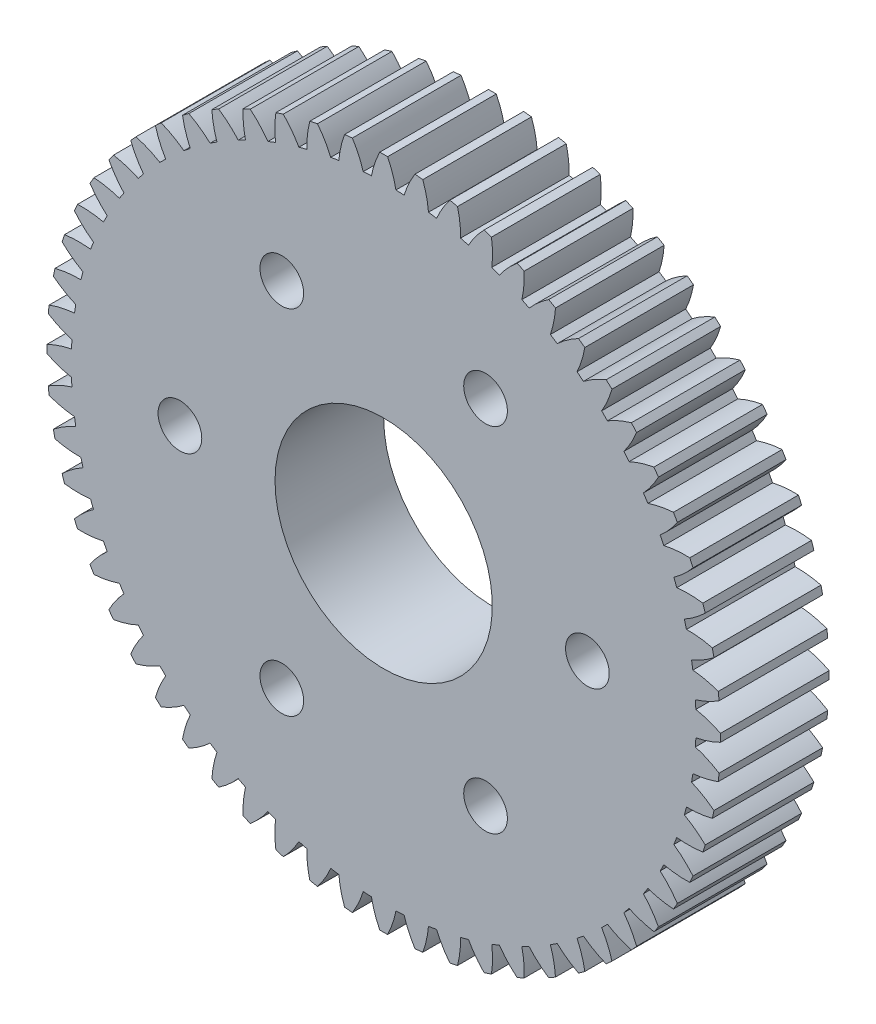
from build123d import *

# Parameters (mm, degrees)
SKETCH1_R              = 39.36992126
BOSS_EXTRUDE1_DEPTH    = 12.6999746
CUT_EXTRUDE1_DEPTH     = 13.6999746
CUT_EXTRUDE2_DEPTH     = 13.6999746
CUT_EXTRUDE3_DEPTH     = 13.6999746
CUT_EXTRUDE4_DEPTH     = 13.6999746
CUT_EXTRUDE5_DEPTH     = 13.6999746
CUT_EXTRUDE6_DEPTH     = 13.6999746
CUT_EXTRUDE7_DEPTH     = 13.6999746
CUT_EXTRUDE8_DEPTH     = 13.6999746
CUT_EXTRUDE9_DEPTH     = 13.6999746
CUT_EXTRUDE10_DEPTH    = 13.6999746
CUT_EXTRUDE11_DEPTH    = 13.6999746
CUT_EXTRUDE12_DEPTH    = 13.6999746
CUT_EXTRUDE13_DEPTH    = 13.6999746
CUT_EXTRUDE14_DEPTH    = 13.6999746
CUT_EXTRUDE15_DEPTH    = 13.6999746
CUT_EXTRUDE16_DEPTH    = 13.6999746
CUT_EXTRUDE17_DEPTH    = 13.6999746
CUT_EXTRUDE18_DEPTH    = 13.6999746
CUT_EXTRUDE19_DEPTH    = 13.6999746
CUT_EXTRUDE20_DEPTH    = 13.6999746
CUT_EXTRUDE21_DEPTH    = 13.6999746
CUT_EXTRUDE22_DEPTH    = 13.6999746
CUT_EXTRUDE23_DEPTH    = 13.6999746
CUT_EXTRUDE24_DEPTH    = 13.6999746
CUT_EXTRUDE25_DEPTH    = 13.6999746
CUT_EXTRUDE26_DEPTH    = 13.6999746
CUT_EXTRUDE27_DEPTH    = 13.6999746
CUT_EXTRUDE28_DEPTH    = 13.6999746
CUT_EXTRUDE29_DEPTH    = 13.6999746
CUT_EXTRUDE30_DEPTH    = 13.6999746
CUT_EXTRUDE31_DEPTH    = 13.6999746
CUT_EXTRUDE32_DEPTH    = 13.6999746
CUT_EXTRUDE33_DEPTH    = 13.6999746
CUT_EXTRUDE34_DEPTH    = 13.6999746
CUT_EXTRUDE35_DEPTH    = 13.6999746
CUT_EXTRUDE36_DEPTH    = 13.6999746
CUT_EXTRUDE37_DEPTH    = 13.6999746
CUT_EXTRUDE38_DEPTH    = 13.6999746
CUT_EXTRUDE39_DEPTH    = 13.6999746
CUT_EXTRUDE40_DEPTH    = 13.6999746
CUT_EXTRUDE41_DEPTH    = 13.6999746
CUT_EXTRUDE42_DEPTH    = 13.6999746
CUT_EXTRUDE43_DEPTH    = 13.6999746
CUT_EXTRUDE44_DEPTH    = 13.6999746
CUT_EXTRUDE45_DEPTH    = 13.6999746
CUT_EXTRUDE46_DEPTH    = 13.6999746
CUT_EXTRUDE47_DEPTH    = 13.6999746
CUT_EXTRUDE48_DEPTH    = 13.6999746
CUT_EXTRUDE49_DEPTH    = 13.6999746
CUT_EXTRUDE50_DEPTH    = 13.6999746
CUT_EXTRUDE51_DEPTH    = 13.6999746
CUT_EXTRUDE52_DEPTH    = 13.6999746
CUT_EXTRUDE53_DEPTH    = 13.6999746
CUT_EXTRUDE54_DEPTH    = 13.6999746
CUT_EXTRUDE55_DEPTH    = 13.6999746
CUT_EXTRUDE56_DEPTH    = 13.6999746
CUT_EXTRUDE57_DEPTH    = 13.6999746
CUT_EXTRUDE58_DEPTH    = 13.6999746
CUT_EXTRUDE59_DEPTH    = 13.6999746
CUT_EXTRUDE60_DEPTH    = 13.6999746
HOLE1_D                = 25.4
HOLE1_DEPTH            = 12.6999746
F_10_CLEARANCE_HOLE1_D = 5.1054


with BuildPart() as part:
    # Sketch1 → Boss-Extrude1 (new body)
    with BuildSketch(Plane.XY):
        with Locations(Location((0, 0, 0), (0, 0, 180))):  # turned: the seam where the file's is
            Circle(SKETCH1_R)
    extrude(amount=-BOSS_EXTRUDE1_DEPTH)

    # Sketch2 → Cut-Extrude1 (cut, through all)
    with BuildSketch(Plane(origin=(0, 0, -12.6999746), x_dir=(-1, 0, 0), z_dir=(0, 0, -1))):
        with BuildLine():
            ThreePointArc((8.632897854, 38.411766097), (8.910906358, 36.912197067), (8.987539423, 35.389001946))
            ThreePointArc((8.987539423, 35.389001946), (9.450111484, 35.268296196), (9.911063515, 35.141544411))
            ThreePointArc((9.911063515, 35.141544411), (10.739027257, 36.422353548), (11.729574199, 37.582014171))
            ThreePointArc((11.729574199, 37.582014171), (10.189685426, 38.028423724), (8.632897854, 38.411766097))
        make_face()
    extrude(amount=-CUT_EXTRUDE1_DEPTH, mode=Mode.SUBTRACT)

    # Sketch3 → Cut-Extrude2 (cut, through all)
    with BuildSketch(Plane(origin=(0, 0, -12.6999746), x_dir=(-1, 0, 0), z_dir=(0, 0, -1))):
        with BuildLine():
            ThreePointArc((12.600728818, 37.298958877), (12.720466716, 35.778544841), (12.637462732, 34.255683606))
            ThreePointArc((12.637462732, 34.255683606), (13.084883588, 34.087287148), (13.530061306, 33.913047115))
            ThreePointArc((13.530061306, 33.913047115), (14.487370387, 35.100294068), (15.593708552, 36.150061599))
            ThreePointArc((15.593708552, 36.150061599), (14.108917956, 36.754987881), (12.600728818, 37.298958877))
        make_face()
    extrude(amount=-CUT_EXTRUDE2_DEPTH, mode=Mode.SUBTRACT)

    # Sketch4 → Cut-Extrude3 (cut, through all)
    with BuildSketch(Plane(origin=(0, 0, -12.6999746), x_dir=(-1, 0, 0), z_dir=(0, 0, -1))):
        with BuildLine():
            ThreePointArc((16.43050356, 35.777496458), (16.390658978, 34.252895391), (16.148927354, 32.747052828))
            ThreePointArc((16.148927354, 32.747052828), (16.576294969, 32.532810649), (17.000820915, 32.312991379))
            ThreePointArc((17.000820915, 32.312991379), (18.076986855, 33.393668422), (19.286994971, 34.322041388))
            ThreePointArc((19.286994971, 34.322041388), (17.873570228, 35.078856699), (16.43050356, 35.777496458))
        make_face()
    extrude(amount=-CUT_EXTRUDE3_DEPTH, mode=Mode.SUBTRACT)

    # Sketch5 → Cut-Extrude4 (cut, through all)
    with BuildSketch(Plane(origin=(0, 0, -12.6999746), x_dir=(-1, 0, 0), z_dir=(0, 0, -1))):
        with BuildLine():
            ThreePointArc((20.080262266, 33.864048301), (19.881271751, 32.351964051), (19.483460949, 30.879638487))
            ThreePointArc((19.483460949, 30.879638487), (19.886092994, 30.621897868), (20.285315971, 30.358907746))
            ThreePointArc((20.285315971, 30.358907746), (21.468548073, 31.321174755), (22.768969036, 32.117981709))
            ThreePointArc((22.768969036, 32.117981709), (21.442395924, 33.018394223), (20.080262266, 33.864048301))
        make_face()
    extrude(amount=-CUT_EXTRUDE4_DEPTH, mode=Mode.SUBTRACT)

    # Sketch6 → Cut-Extrude5 (cut, through all)
    with BuildSketch(Plane(origin=(0, 0, -12.6999746), x_dir=(-1, 0, 0), z_dir=(0, 0, -1))):
        with BuildLine():
            ThreePointArc((23.510017418, 31.579578544), (23.15406115, 30.096577823), (22.604529668, 28.673900364))
            ThreePointArc((22.604529668, 28.673900364), (22.978014822, 28.375485167), (23.347560861, 28.072205568))
            ThreePointArc((23.347560861, 28.072205568), (24.624895385, 28.905519744), (26.001481513, 29.562030701))
            ThreePointArc((26.001481513, 29.562030701), (24.776294243, 30.59617531), (23.510017418, 31.579578544))
        make_face()
    extrude(amount=-CUT_EXTRUDE5_DEPTH, mode=Mode.SUBTRACT)

    # Sketch7 → Cut-Extrude6 (cut, through all)
    with BuildSketch(Plane(origin=(0, 0, -12.6999746), x_dir=(-1, 0, 0), z_dir=(0, 0, -1))):
        with BuildLine():
            ThreePointArc((26.682191898, 28.949116317), (26.17316981, 27.511447191), (25.477938431, 26.154004988))
            ThreePointArc((25.477938431, 26.154004988), (25.818184712, 25.818184712), (26.154004988, 25.477938431))
            ThreePointArc((26.154004988, 25.477938431), (27.511447191, 26.17316981), (28.949116317, 26.682191898))
            ThreePointArc((28.949116317, 26.682191898), (27.838738298, 27.838738298), (26.682191898, 28.949116317))
        make_face()
    extrude(amount=-CUT_EXTRUDE6_DEPTH, mode=Mode.SUBTRACT)

    # Sketch8 → Cut-Extrude7 (cut, through all)
    with BuildSketch(Plane(origin=(0, 0, -12.6999746), x_dir=(-1, 0, 0), z_dir=(0, 0, -1))):
        with BuildLine():
            ThreePointArc((29.562030701, 26.001481513), (28.905519744, 24.624895385), (28.072205568, 23.347560861))
            ThreePointArc((28.072205568, 23.347560861), (28.375485167, 22.978014822), (28.673900364, 22.604529668))
            ThreePointArc((28.673900364, 22.604529668), (30.096577823, 23.15406115), (31.579578544, 23.510017418))
            ThreePointArc((31.579578544, 23.510017418), (30.59617531, 24.776294243), (29.562030701, 26.001481513))
        make_face()
    extrude(amount=-CUT_EXTRUDE7_DEPTH, mode=Mode.SUBTRACT)

    # Sketch9 → Cut-Extrude8 (cut, through all)
    with BuildSketch(Plane(origin=(0, 0, -12.6999746), x_dir=(-1, 0, 0), z_dir=(0, 0, -1))):
        with BuildLine():
            ThreePointArc((32.117981709, 22.768969036), (31.321174755, 21.468548073), (30.358907746, 20.285315971))
            ThreePointArc((30.358907746, 20.285315971), (30.621897868, 19.886092994), (30.879638487, 19.483460949))
            ThreePointArc((30.879638487, 19.483460949), (32.351964051, 19.881271751), (33.864048301, 20.080262266))
            ThreePointArc((33.864048301, 20.080262266), (33.018394223, 21.442395924), (32.117981709, 22.768969036))
        make_face()
    extrude(amount=-CUT_EXTRUDE8_DEPTH, mode=Mode.SUBTRACT)

    # Sketch10 → Cut-Extrude9 (cut, through all)
    with BuildSketch(Plane(origin=(0, 0, -12.6999746), x_dir=(-1, 0, 0), z_dir=(0, 0, -1))):
        with BuildLine():
            ThreePointArc((34.322041388, 19.286994971), (33.393668422, 18.076986855), (32.312991379, 17.000820915))
            ThreePointArc((32.312991379, 17.000820915), (32.532810649, 16.576294969), (32.747052828, 16.148927354))
            ThreePointArc((32.747052828, 16.148927354), (34.252895391, 16.390658978), (35.777496458, 16.43050356))
            ThreePointArc((35.777496458, 16.43050356), (35.078856699, 17.873570228), (34.322041388, 19.286994971))
        make_face()
    extrude(amount=-CUT_EXTRUDE9_DEPTH, mode=Mode.SUBTRACT)

    # Sketch11 → Cut-Extrude10 (cut, through all)
    with BuildSketch(Plane(origin=(0, 0, -12.6999746), x_dir=(-1, 0, 0), z_dir=(0, 0, -1))):
        with BuildLine():
            ThreePointArc((36.150061599, 15.593708552), (35.100294068, 14.487370387), (33.913047115, 13.530061306))
            ThreePointArc((33.913047115, 13.530061306), (34.087287148, 13.084883588), (34.255683606, 12.637462732))
            ThreePointArc((34.255683606, 12.637462732), (35.778544841, 12.720466716), (37.298958877, 12.600728818))
            ThreePointArc((37.298958877, 12.600728818), (36.754987881, 14.108917956), (36.150061599, 15.593708552))
        make_face()
    extrude(amount=-CUT_EXTRUDE10_DEPTH, mode=Mode.SUBTRACT)

    # Sketch12 → Cut-Extrude11 (cut, through all)
    with BuildSketch(Plane(origin=(0, 0, -12.6999746), x_dir=(-1, 0, 0), z_dir=(0, 0, -1))):
        with BuildLine():
            ThreePointArc((37.582014171, 11.729574199), (36.422353548, 10.739027257), (35.141544411, 9.911063515))
            ThreePointArc((35.141544411, 9.911063515), (35.268296196, 9.450111484), (35.389001946, 8.987539423))
            ThreePointArc((35.389001946, 8.987539423), (36.912197067, 8.910906358), (38.411766097, 8.632897854))
            ThreePointArc((38.411766097, 8.632897854), (38.028423724, 10.189685426), (37.582014171, 11.729574199))
        make_face()
    extrude(amount=-CUT_EXTRUDE11_DEPTH, mode=Mode.SUBTRACT)

    # Sketch13 → Cut-Extrude12 (cut, through all)
    with BuildSketch(Plane(origin=(0, 0, -12.6999746), x_dir=(-1, 0, 0), z_dir=(0, 0, -1))):
        with BuildLine():
            ThreePointArc((38.602210331, 7.736928176), (37.345362101, 6.873025097), (35.985023593, 6.183478038))
            ThreePointArc((35.985023593, 6.183478038), (36.06289841, 5.711801981), (36.134590975, 5.239146752))
            ThreePointArc((36.134590975, 5.239146752), (37.641431537, 5.003716245), (39.103725969, 4.570483055))
            ThreePointArc((39.103725969, 4.570483055), (38.885212199, 6.158812571), (38.602210331, 7.736928176))
        make_face()
    extrude(amount=-CUT_EXTRUDE12_DEPTH, mode=Mode.SUBTRACT)

    # Sketch14 → Cut-Extrude13 (cut, through all)
    with BuildSketch(Plane(origin=(0, 0, -12.6999746), x_dir=(-1, 0, 0), z_dir=(0, 0, -1))):
        with BuildLine():
            ThreePointArc((39.199472596, 3.659514749), (37.859207051, 2.931720636), (36.434243325, 2.388145082))
            ThreePointArc((36.434243325, 2.388145082), (36.462387963, 1.91091278), (36.484281863, 1.433352892))
            ThreePointArc((36.484281863, 1.433352892), (37.958258606, 1.04170437), (39.367257237, 0.457993087))
            ThreePointArc((39.367257237, 0.457993087), (39.315966151, 2.060462476), (39.199472596, 3.659514749))
        make_face()
    extrude(amount=-CUT_EXTRUDE13_DEPTH, mode=Mode.SUBTRACT)

    # Sketch15 → Cut-Extrude14 (cut, through all)
    with BuildSketch(Plane(origin=(0, 0, -12.6999746), x_dir=(-1, 0, 0), z_dir=(0, 0, -1))):
        with BuildLine():
            ThreePointArc((39.367257237, -0.457993087), (37.958258606, -1.04170437), (36.484281863, -1.433352892))
            ThreePointArc((36.484281863, -1.433352892), (36.462387963, -1.91091278), (36.434243325, -2.388145082))
            ThreePointArc((36.434243325, -2.388145082), (37.859207051, -2.931720636), (39.199472596, -3.659514749))
            ThreePointArc((39.199472596, -3.659514749), (39.315966151, -2.060462476), (39.367257237, -0.457993087))
        make_face()
    extrude(amount=-CUT_EXTRUDE14_DEPTH, mode=Mode.SUBTRACT)

    # Sketch16 → Cut-Extrude15 (cut, through all)
    with BuildSketch(Plane(origin=(0, 0, -12.6999746), x_dir=(-1, 0, 0), z_dir=(0, 0, -1))):
        with BuildLine():
            ThreePointArc((39.103725969, -4.570483055), (37.641431537, -5.003716245), (36.134590975, -5.239146752))
            ThreePointArc((36.134590975, -5.239146752), (36.06289841, -5.711801981), (35.985023593, -6.183478038))
            ThreePointArc((35.985023593, -6.183478038), (37.345362101, -6.873025097), (38.602210331, -7.736928176))
            ThreePointArc((38.602210331, -7.736928176), (38.885212199, -6.158812571), (39.103725969, -4.570483055))
        make_face()
    extrude(amount=-CUT_EXTRUDE15_DEPTH, mode=Mode.SUBTRACT)

    # Sketch17 → Cut-Extrude16 (cut, through all)
    with BuildSketch(Plane(origin=(0, 0, -12.6999746), x_dir=(-1, 0, 0), z_dir=(0, 0, -1))):
        with BuildLine():
            ThreePointArc((38.411766097, -8.632897854), (36.912197067, -8.910906358), (35.389001946, -8.987539423))
            ThreePointArc((35.389001946, -8.987539423), (35.268296196, -9.450111484), (35.141544411, -9.911063515))
            ThreePointArc((35.141544411, -9.911063515), (36.422353548, -10.739027257), (37.582014171, -11.729574199))
            ThreePointArc((37.582014171, -11.729574199), (38.028423724, -10.189685426), (38.411766097, -8.632897854))
        make_face()
    extrude(amount=-CUT_EXTRUDE16_DEPTH, mode=Mode.SUBTRACT)

    # Sketch18 → Cut-Extrude17 (cut, through all)
    with BuildSketch(Plane(origin=(0, 0, -12.6999746), x_dir=(-1, 0, 0), z_dir=(0, 0, -1))):
        with BuildLine():
            ThreePointArc((37.298958877, -12.600728818), (35.778544841, -12.720466716), (34.255683606, -12.637462732))
            ThreePointArc((34.255683606, -12.637462732), (34.087287148, -13.084883588), (33.913047115, -13.530061306))
            ThreePointArc((33.913047115, -13.530061306), (35.100294068, -14.487370387), (36.150061599, -15.593708552))
            ThreePointArc((36.150061599, -15.593708552), (36.754987881, -14.108917956), (37.298958877, -12.600728818))
        make_face()
    extrude(amount=-CUT_EXTRUDE17_DEPTH, mode=Mode.SUBTRACT)

    # Sketch19 → Cut-Extrude18 (cut, through all)
    with BuildSketch(Plane(origin=(0, 0, -12.6999746), x_dir=(-1, 0, 0), z_dir=(0, 0, -1))):
        with BuildLine():
            ThreePointArc((35.777496458, -16.43050356), (34.252895391, -16.390658978), (32.747052828, -16.148927354))
            ThreePointArc((32.747052828, -16.148927354), (32.532810649, -16.576294969), (32.312991379, -17.000820915))
            ThreePointArc((32.312991379, -17.000820915), (33.393668422, -18.076986855), (34.322041388, -19.286994971))
            ThreePointArc((34.322041388, -19.286994971), (35.078856699, -17.873570228), (35.777496458, -16.43050356))
        make_face()
    extrude(amount=-CUT_EXTRUDE18_DEPTH, mode=Mode.SUBTRACT)

    # Sketch20 → Cut-Extrude19 (cut, through all)
    with BuildSketch(Plane(origin=(0, 0, -12.6999746), x_dir=(-1, 0, 0), z_dir=(0, 0, -1))):
        with BuildLine():
            ThreePointArc((33.864048301, -20.080262266), (32.351964051, -19.881271751), (30.879638487, -19.483460949))
            ThreePointArc((30.879638487, -19.483460949), (30.621897868, -19.886092994), (30.358907746, -20.285315971))
            ThreePointArc((30.358907746, -20.285315971), (31.321174755, -21.468548073), (32.117981709, -22.768969036))
            ThreePointArc((32.117981709, -22.768969036), (33.018394223, -21.442395924), (33.864048301, -20.080262266))
        make_face()
    extrude(amount=-CUT_EXTRUDE19_DEPTH, mode=Mode.SUBTRACT)

    # Sketch21 → Cut-Extrude20 (cut, through all)
    with BuildSketch(Plane(origin=(0, 0, -12.6999746), x_dir=(-1, 0, 0), z_dir=(0, 0, -1))):
        with BuildLine():
            ThreePointArc((31.579578544, -23.510017418), (30.096577823, -23.15406115), (28.673900364, -22.604529668))
            ThreePointArc((28.673900364, -22.604529668), (28.375485167, -22.978014822), (28.072205568, -23.347560861))
            ThreePointArc((28.072205568, -23.347560861), (28.905519744, -24.624895385), (29.562030701, -26.001481513))
            ThreePointArc((29.562030701, -26.001481513), (30.59617531, -24.776294243), (31.579578544, -23.510017418))
        make_face()
    extrude(amount=-CUT_EXTRUDE20_DEPTH, mode=Mode.SUBTRACT)

    # Sketch22 → Cut-Extrude21 (cut, through all)
    with BuildSketch(Plane(origin=(0, 0, -12.6999746), x_dir=(-1, 0, 0), z_dir=(0, 0, -1))):
        with BuildLine():
            ThreePointArc((28.949116317, -26.682191898), (27.511447191, -26.17316981), (26.154004988, -25.477938431))
            ThreePointArc((26.154004988, -25.477938431), (25.818184712, -25.818184712), (25.477938431, -26.154004988))
            ThreePointArc((25.477938431, -26.154004988), (26.17316981, -27.511447191), (26.682191898, -28.949116317))
            ThreePointArc((26.682191898, -28.949116317), (27.838738298, -27.838738298), (28.949116317, -26.682191898))
        make_face()
    extrude(amount=-CUT_EXTRUDE21_DEPTH, mode=Mode.SUBTRACT)

    # Sketch23 → Cut-Extrude22 (cut, through all)
    with BuildSketch(Plane(origin=(0, 0, -12.6999746), x_dir=(-1, 0, 0), z_dir=(0, 0, -1))):
        with BuildLine():
            ThreePointArc((26.001481513, -29.562030701), (24.624895385, -28.905519744), (23.347560861, -28.072205568))
            ThreePointArc((23.347560861, -28.072205568), (22.978014822, -28.375485167), (22.604529668, -28.673900364))
            ThreePointArc((22.604529668, -28.673900364), (23.15406115, -30.096577823), (23.510017418, -31.579578544))
            ThreePointArc((23.510017418, -31.579578544), (24.776294243, -30.59617531), (26.001481513, -29.562030701))
        make_face()
    extrude(amount=-CUT_EXTRUDE22_DEPTH, mode=Mode.SUBTRACT)

    # Sketch24 → Cut-Extrude23 (cut, through all)
    with BuildSketch(Plane(origin=(0, 0, -12.6999746), x_dir=(-1, 0, 0), z_dir=(0, 0, -1))):
        with BuildLine():
            ThreePointArc((22.768969036, -32.117981709), (21.468548073, -31.321174755), (20.285315971, -30.358907746))
            ThreePointArc((20.285315971, -30.358907746), (19.886092994, -30.621897868), (19.483460949, -30.879638487))
            ThreePointArc((19.483460949, -30.879638487), (19.881271751, -32.351964051), (20.080262266, -33.864048301))
            ThreePointArc((20.080262266, -33.864048301), (21.442395924, -33.018394223), (22.768969036, -32.117981709))
        make_face()
    extrude(amount=-CUT_EXTRUDE23_DEPTH, mode=Mode.SUBTRACT)

    # Sketch25 → Cut-Extrude24 (cut, through all)
    with BuildSketch(Plane(origin=(0, 0, -12.6999746), x_dir=(-1, 0, 0), z_dir=(0, 0, -1))):
        with BuildLine():
            ThreePointArc((19.286994971, -34.322041388), (18.076986855, -33.393668422), (17.000820915, -32.312991379))
            ThreePointArc((17.000820915, -32.312991379), (16.576294969, -32.532810649), (16.148927354, -32.747052828))
            ThreePointArc((16.148927354, -32.747052828), (16.390658978, -34.252895391), (16.43050356, -35.777496458))
            ThreePointArc((16.43050356, -35.777496458), (17.873570228, -35.078856699), (19.286994971, -34.322041388))
        make_face()
    extrude(amount=-CUT_EXTRUDE24_DEPTH, mode=Mode.SUBTRACT)

    # Sketch26 → Cut-Extrude25 (cut, through all)
    with BuildSketch(Plane(origin=(0, 0, -12.6999746), x_dir=(-1, 0, 0), z_dir=(0, 0, -1))):
        with BuildLine():
            ThreePointArc((15.593708552, -36.150061599), (14.487370387, -35.100294068), (13.530061306, -33.913047115))
            ThreePointArc((13.530061306, -33.913047115), (13.084883588, -34.087287148), (12.637462732, -34.255683606))
            ThreePointArc((12.637462732, -34.255683606), (12.720466716, -35.778544841), (12.600728818, -37.298958877))
            ThreePointArc((12.600728818, -37.298958877), (14.108917956, -36.754987881), (15.593708552, -36.150061599))
        make_face()
    extrude(amount=-CUT_EXTRUDE25_DEPTH, mode=Mode.SUBTRACT)

    # Sketch27 → Cut-Extrude26 (cut, through all)
    with BuildSketch(Plane(origin=(0, 0, -12.6999746), x_dir=(-1, 0, 0), z_dir=(0, 0, -1))):
        with BuildLine():
            ThreePointArc((11.729574199, -37.582014171), (10.739027257, -36.422353548), (9.911063515, -35.141544411))
            ThreePointArc((9.911063515, -35.141544411), (9.450111484, -35.268296196), (8.987539423, -35.389001946))
            ThreePointArc((8.987539423, -35.389001946), (8.910906358, -36.912197067), (8.632897854, -38.411766097))
            ThreePointArc((8.632897854, -38.411766097), (10.189685426, -38.028423724), (11.729574199, -37.582014171))
        make_face()
    extrude(amount=-CUT_EXTRUDE26_DEPTH, mode=Mode.SUBTRACT)

    # Sketch28 → Cut-Extrude27 (cut, through all)
    with BuildSketch(Plane(origin=(0, 0, -12.6999746), x_dir=(-1, 0, 0), z_dir=(0, 0, -1))):
        with BuildLine():
            ThreePointArc((7.736928176, -38.602210331), (6.873025097, -37.345362101), (6.183478038, -35.985023593))
            ThreePointArc((6.183478038, -35.985023593), (5.711801981, -36.06289841), (5.239146752, -36.134590975))
            ThreePointArc((5.239146752, -36.134590975), (5.003716245, -37.641431537), (4.570483055, -39.103725969))
            ThreePointArc((4.570483055, -39.103725969), (6.158812571, -38.885212199), (7.736928176, -38.602210331))
        make_face()
    extrude(amount=-CUT_EXTRUDE27_DEPTH, mode=Mode.SUBTRACT)

    # Sketch29 → Cut-Extrude28 (cut, through all)
    with BuildSketch(Plane(origin=(0, 0, -12.6999746), x_dir=(-1, 0, 0), z_dir=(0, 0, -1))):
        with BuildLine():
            ThreePointArc((3.659514749, -39.199472596), (2.931720636, -37.859207051), (2.388145082, -36.434243325))
            ThreePointArc((2.388145082, -36.434243325), (1.91091278, -36.462387963), (1.433352892, -36.484281863))
            ThreePointArc((1.433352892, -36.484281863), (1.04170437, -37.958258606), (0.457993087, -39.367257237))
            ThreePointArc((0.457993087, -39.367257237), (2.060462476, -39.315966151), (3.659514749, -39.199472596))
        make_face()
    extrude(amount=-CUT_EXTRUDE28_DEPTH, mode=Mode.SUBTRACT)

    # Sketch30 → Cut-Extrude29 (cut, through all)
    with BuildSketch(Plane(origin=(0, 0, -12.6999746), x_dir=(-1, 0, 0), z_dir=(0, 0, -1))):
        with BuildLine():
            ThreePointArc((-0.457993087, -39.367257237), (-1.04170437, -37.958258606), (-1.433352892, -36.484281863))
            ThreePointArc((-1.433352892, -36.484281863), (-1.91091278, -36.462387963), (-2.388145082, -36.434243325))
            ThreePointArc((-2.388145082, -36.434243325), (-2.931720636, -37.859207051), (-3.659514749, -39.199472596))
            ThreePointArc((-3.659514749, -39.199472596), (-2.060462476, -39.315966151), (-0.457993087, -39.367257237))
        make_face()
    extrude(amount=-CUT_EXTRUDE29_DEPTH, mode=Mode.SUBTRACT)

    # Sketch31 → Cut-Extrude30 (cut, through all)
    with BuildSketch(Plane(origin=(0, 0, -12.6999746), x_dir=(-1, 0, 0), z_dir=(0, 0, -1))):
        with BuildLine():
            ThreePointArc((-4.570483055, -39.103725969), (-5.003716245, -37.641431537), (-5.239146752, -36.134590975))
            ThreePointArc((-5.239146752, -36.134590975), (-5.711801981, -36.06289841), (-6.183478038, -35.985023593))
            ThreePointArc((-6.183478038, -35.985023593), (-6.873025097, -37.345362101), (-7.736928176, -38.602210331))
            ThreePointArc((-7.736928176, -38.602210331), (-6.158812571, -38.885212199), (-4.570483055, -39.103725969))
        make_face()
    extrude(amount=-CUT_EXTRUDE30_DEPTH, mode=Mode.SUBTRACT)

    # Sketch32 → Cut-Extrude31 (cut, through all)
    with BuildSketch(Plane(origin=(0, 0, -12.6999746), x_dir=(-1, 0, 0), z_dir=(0, 0, -1))):
        with BuildLine():
            ThreePointArc((-8.632897854, -38.411766097), (-8.910906358, -36.912197067), (-8.987539423, -35.389001946))
            ThreePointArc((-8.987539423, -35.389001946), (-9.450111484, -35.268296196), (-9.911063515, -35.141544411))
            ThreePointArc((-9.911063515, -35.141544411), (-10.739027257, -36.422353548), (-11.729574199, -37.582014171))
            ThreePointArc((-11.729574199, -37.582014171), (-10.189685426, -38.028423724), (-8.632897854, -38.411766097))
        make_face()
    extrude(amount=-CUT_EXTRUDE31_DEPTH, mode=Mode.SUBTRACT)

    # Sketch33 → Cut-Extrude32 (cut, through all)
    with BuildSketch(Plane(origin=(0, 0, -12.6999746), x_dir=(-1, 0, 0), z_dir=(0, 0, -1))):
        with BuildLine():
            ThreePointArc((-12.600728818, -37.298958877), (-12.720466716, -35.778544841), (-12.637462732, -34.255683606))
            ThreePointArc((-12.637462732, -34.255683606), (-13.084883588, -34.087287148), (-13.530061306, -33.913047115))
            ThreePointArc((-13.530061306, -33.913047115), (-14.487370387, -35.100294068), (-15.593708552, -36.150061599))
            ThreePointArc((-15.593708552, -36.150061599), (-14.108917956, -36.754987881), (-12.600728818, -37.298958877))
        make_face()
    extrude(amount=-CUT_EXTRUDE32_DEPTH, mode=Mode.SUBTRACT)

    # Sketch34 → Cut-Extrude33 (cut, through all)
    with BuildSketch(Plane(origin=(0, 0, -12.6999746), x_dir=(-1, 0, 0), z_dir=(0, 0, -1))):
        with BuildLine():
            ThreePointArc((-16.43050356, -35.777496458), (-16.390658978, -34.252895391), (-16.148927354, -32.747052828))
            ThreePointArc((-16.148927354, -32.747052828), (-16.576294969, -32.532810649), (-17.000820915, -32.312991379))
            ThreePointArc((-17.000820915, -32.312991379), (-18.076986855, -33.393668422), (-19.286994971, -34.322041388))
            ThreePointArc((-19.286994971, -34.322041388), (-17.873570228, -35.078856699), (-16.43050356, -35.777496458))
        make_face()
    extrude(amount=-CUT_EXTRUDE33_DEPTH, mode=Mode.SUBTRACT)

    # Sketch35 → Cut-Extrude34 (cut, through all)
    with BuildSketch(Plane(origin=(0, 0, -12.6999746), x_dir=(-1, 0, 0), z_dir=(0, 0, -1))):
        with BuildLine():
            ThreePointArc((-20.080262266, -33.864048301), (-19.881271751, -32.351964051), (-19.483460949, -30.879638487))
            ThreePointArc((-19.483460949, -30.879638487), (-19.886092994, -30.621897868), (-20.285315971, -30.358907746))
            ThreePointArc((-20.285315971, -30.358907746), (-21.468548073, -31.321174755), (-22.768969036, -32.117981709))
            ThreePointArc((-22.768969036, -32.117981709), (-21.442395924, -33.018394223), (-20.080262266, -33.864048301))
        make_face()
    extrude(amount=-CUT_EXTRUDE34_DEPTH, mode=Mode.SUBTRACT)

    # Sketch36 → Cut-Extrude35 (cut, through all)
    with BuildSketch(Plane(origin=(0, 0, -12.6999746), x_dir=(-1, 0, 0), z_dir=(0, 0, -1))):
        with BuildLine():
            ThreePointArc((-23.510017418, -31.579578544), (-23.15406115, -30.096577823), (-22.604529668, -28.673900364))
            ThreePointArc((-22.604529668, -28.673900364), (-22.978014822, -28.375485167), (-23.347560861, -28.072205568))
            ThreePointArc((-23.347560861, -28.072205568), (-24.624895385, -28.905519744), (-26.001481513, -29.562030701))
            ThreePointArc((-26.001481513, -29.562030701), (-24.776294243, -30.59617531), (-23.510017418, -31.579578544))
        make_face()
    extrude(amount=-CUT_EXTRUDE35_DEPTH, mode=Mode.SUBTRACT)

    # Sketch37 → Cut-Extrude36 (cut, through all)
    with BuildSketch(Plane(origin=(0, 0, -12.6999746), x_dir=(-1, 0, 0), z_dir=(0, 0, -1))):
        with BuildLine():
            ThreePointArc((-26.682191898, -28.949116317), (-26.17316981, -27.511447191), (-25.477938431, -26.154004988))
            ThreePointArc((-25.477938431, -26.154004988), (-25.818184712, -25.818184712), (-26.154004988, -25.477938431))
            ThreePointArc((-26.154004988, -25.477938431), (-27.511447191, -26.17316981), (-28.949116317, -26.682191898))
            ThreePointArc((-28.949116317, -26.682191898), (-27.838738298, -27.838738298), (-26.682191898, -28.949116317))
        make_face()
    extrude(amount=-CUT_EXTRUDE36_DEPTH, mode=Mode.SUBTRACT)

    # Sketch38 → Cut-Extrude37 (cut, through all)
    with BuildSketch(Plane(origin=(0, 0, -12.6999746), x_dir=(-1, 0, 0), z_dir=(0, 0, -1))):
        with BuildLine():
            ThreePointArc((-29.562030701, -26.001481513), (-28.905519744, -24.624895385), (-28.072205568, -23.347560861))
            ThreePointArc((-28.072205568, -23.347560861), (-28.375485167, -22.978014822), (-28.673900364, -22.604529668))
            ThreePointArc((-28.673900364, -22.604529668), (-30.096577823, -23.15406115), (-31.579578544, -23.510017418))
            ThreePointArc((-31.579578544, -23.510017418), (-30.59617531, -24.776294243), (-29.562030701, -26.001481513))
        make_face()
    extrude(amount=-CUT_EXTRUDE37_DEPTH, mode=Mode.SUBTRACT)

    # Sketch39 → Cut-Extrude38 (cut, through all)
    with BuildSketch(Plane(origin=(0, 0, -12.6999746), x_dir=(-1, 0, 0), z_dir=(0, 0, -1))):
        with BuildLine():
            ThreePointArc((-32.117981709, -22.768969036), (-31.321174755, -21.468548073), (-30.358907746, -20.285315971))
            ThreePointArc((-30.358907746, -20.285315971), (-30.621897868, -19.886092994), (-30.879638487, -19.483460949))
            ThreePointArc((-30.879638487, -19.483460949), (-32.351964051, -19.881271751), (-33.864048301, -20.080262266))
            ThreePointArc((-33.864048301, -20.080262266), (-33.018394223, -21.442395924), (-32.117981709, -22.768969036))
        make_face()
    extrude(amount=-CUT_EXTRUDE38_DEPTH, mode=Mode.SUBTRACT)

    # Sketch40 → Cut-Extrude39 (cut, through all)
    with BuildSketch(Plane(origin=(0, 0, -12.6999746), x_dir=(-1, 0, 0), z_dir=(0, 0, -1))):
        with BuildLine():
            ThreePointArc((-34.322041388, -19.286994971), (-33.393668422, -18.076986855), (-32.312991379, -17.000820915))
            ThreePointArc((-32.312991379, -17.000820915), (-32.532810649, -16.576294969), (-32.747052828, -16.148927354))
            ThreePointArc((-32.747052828, -16.148927354), (-34.252895391, -16.390658978), (-35.777496458, -16.43050356))
            ThreePointArc((-35.777496458, -16.43050356), (-35.078856699, -17.873570228), (-34.322041388, -19.286994971))
        make_face()
    extrude(amount=-CUT_EXTRUDE39_DEPTH, mode=Mode.SUBTRACT)

    # Sketch41 → Cut-Extrude40 (cut, through all)
    with BuildSketch(Plane(origin=(0, 0, -12.6999746), x_dir=(-1, 0, 0), z_dir=(0, 0, -1))):
        with BuildLine():
            ThreePointArc((-36.150061599, -15.593708552), (-35.100294068, -14.487370387), (-33.913047115, -13.530061306))
            ThreePointArc((-33.913047115, -13.530061306), (-34.087287148, -13.084883588), (-34.255683606, -12.637462732))
            ThreePointArc((-34.255683606, -12.637462732), (-35.778544841, -12.720466716), (-37.298958877, -12.600728818))
            ThreePointArc((-37.298958877, -12.600728818), (-36.754987881, -14.108917956), (-36.150061599, -15.593708552))
        make_face()
    extrude(amount=-CUT_EXTRUDE40_DEPTH, mode=Mode.SUBTRACT)

    # Sketch42 → Cut-Extrude41 (cut, through all)
    with BuildSketch(Plane(origin=(0, 0, -12.6999746), x_dir=(-1, 0, 0), z_dir=(0, 0, -1))):
        with BuildLine():
            ThreePointArc((-37.582014171, -11.729574199), (-36.422353548, -10.739027257), (-35.141544411, -9.911063515))
            ThreePointArc((-35.141544411, -9.911063515), (-35.268296196, -9.450111484), (-35.389001946, -8.987539423))
            ThreePointArc((-35.389001946, -8.987539423), (-36.912197067, -8.910906358), (-38.411766097, -8.632897854))
            ThreePointArc((-38.411766097, -8.632897854), (-38.028423724, -10.189685426), (-37.582014171, -11.729574199))
        make_face()
    extrude(amount=-CUT_EXTRUDE41_DEPTH, mode=Mode.SUBTRACT)

    # Sketch43 → Cut-Extrude42 (cut, through all)
    with BuildSketch(Plane(origin=(0, 0, -12.6999746), x_dir=(-1, 0, 0), z_dir=(0, 0, -1))):
        with BuildLine():
            ThreePointArc((-38.602210331, -7.736928176), (-37.345362101, -6.873025097), (-35.985023593, -6.183478038))
            ThreePointArc((-35.985023593, -6.183478038), (-36.06289841, -5.711801981), (-36.134590975, -5.239146752))
            ThreePointArc((-36.134590975, -5.239146752), (-37.641431537, -5.003716245), (-39.103725969, -4.570483055))
            ThreePointArc((-39.103725969, -4.570483055), (-38.885212199, -6.158812571), (-38.602210331, -7.736928176))
        make_face()
    extrude(amount=-CUT_EXTRUDE42_DEPTH, mode=Mode.SUBTRACT)

    # Sketch44 → Cut-Extrude43 (cut, through all)
    with BuildSketch(Plane(origin=(0, 0, -12.6999746), x_dir=(-1, 0, 0), z_dir=(0, 0, -1))):
        with BuildLine():
            ThreePointArc((-39.199472596, -3.659514749), (-37.859207051, -2.931720636), (-36.434243325, -2.388145082))
            ThreePointArc((-36.434243325, -2.388145082), (-36.462387963, -1.91091278), (-36.484281863, -1.433352892))
            ThreePointArc((-36.484281863, -1.433352892), (-37.958258606, -1.04170437), (-39.367257237, -0.457993087))
            ThreePointArc((-39.367257237, -0.457993087), (-39.315966151, -2.060462476), (-39.199472596, -3.659514749))
        make_face()
    extrude(amount=-CUT_EXTRUDE43_DEPTH, mode=Mode.SUBTRACT)

    # Sketch45 → Cut-Extrude44 (cut, through all)
    with BuildSketch(Plane(origin=(0, 0, -12.6999746), x_dir=(-1, 0, 0), z_dir=(0, 0, -1))):
        with BuildLine():
            ThreePointArc((-39.367257237, 0.457993087), (-37.958258606, 1.04170437), (-36.484281863, 1.433352892))
            ThreePointArc((-36.484281863, 1.433352892), (-36.462387963, 1.91091278), (-36.434243325, 2.388145082))
            ThreePointArc((-36.434243325, 2.388145082), (-37.859207051, 2.931720636), (-39.199472596, 3.659514749))
            ThreePointArc((-39.199472596, 3.659514749), (-39.315966151, 2.060462476), (-39.367257237, 0.457993087))
        make_face()
    extrude(amount=-CUT_EXTRUDE44_DEPTH, mode=Mode.SUBTRACT)

    # Sketch46 → Cut-Extrude45 (cut, through all)
    with BuildSketch(Plane(origin=(0, 0, -12.6999746), x_dir=(-1, 0, 0), z_dir=(0, 0, -1))):
        with BuildLine():
            ThreePointArc((-39.103725969, 4.570483055), (-37.641431537, 5.003716245), (-36.134590975, 5.239146752))
            ThreePointArc((-36.134590975, 5.239146752), (-36.06289841, 5.711801981), (-35.985023593, 6.183478038))
            ThreePointArc((-35.985023593, 6.183478038), (-37.345362101, 6.873025097), (-38.602210331, 7.736928176))
            ThreePointArc((-38.602210331, 7.736928176), (-38.885212199, 6.158812571), (-39.103725969, 4.570483055))
        make_face()
    extrude(amount=-CUT_EXTRUDE45_DEPTH, mode=Mode.SUBTRACT)

    # Sketch47 → Cut-Extrude46 (cut, through all)
    with BuildSketch(Plane(origin=(0, 0, -12.6999746), x_dir=(-1, 0, 0), z_dir=(0, 0, -1))):
        with BuildLine():
            ThreePointArc((-38.411766097, 8.632897854), (-36.912197067, 8.910906358), (-35.389001946, 8.987539423))
            ThreePointArc((-35.389001946, 8.987539423), (-35.268296196, 9.450111484), (-35.141544411, 9.911063515))
            ThreePointArc((-35.141544411, 9.911063515), (-36.422353548, 10.739027257), (-37.582014171, 11.729574199))
            ThreePointArc((-37.582014171, 11.729574199), (-38.028423724, 10.189685426), (-38.411766097, 8.632897854))
        make_face()
    extrude(amount=-CUT_EXTRUDE46_DEPTH, mode=Mode.SUBTRACT)

    # Sketch48 → Cut-Extrude47 (cut, through all)
    with BuildSketch(Plane(origin=(0, 0, -12.6999746), x_dir=(-1, 0, 0), z_dir=(0, 0, -1))):
        with BuildLine():
            ThreePointArc((-37.298958877, 12.600728818), (-35.778544841, 12.720466716), (-34.255683606, 12.637462732))
            ThreePointArc((-34.255683606, 12.637462732), (-34.087287148, 13.084883588), (-33.913047115, 13.530061306))
            ThreePointArc((-33.913047115, 13.530061306), (-35.100294068, 14.487370387), (-36.150061599, 15.593708552))
            ThreePointArc((-36.150061599, 15.593708552), (-36.754987881, 14.108917956), (-37.298958877, 12.600728818))
        make_face()
    extrude(amount=-CUT_EXTRUDE47_DEPTH, mode=Mode.SUBTRACT)

    # Sketch49 → Cut-Extrude48 (cut, through all)
    with BuildSketch(Plane(origin=(0, 0, -12.6999746), x_dir=(-1, 0, 0), z_dir=(0, 0, -1))):
        with BuildLine():
            ThreePointArc((-35.777496458, 16.43050356), (-34.252895391, 16.390658978), (-32.747052828, 16.148927354))
            ThreePointArc((-32.747052828, 16.148927354), (-32.532810649, 16.576294969), (-32.312991379, 17.000820915))
            ThreePointArc((-32.312991379, 17.000820915), (-33.393668422, 18.076986855), (-34.322041388, 19.286994971))
            ThreePointArc((-34.322041388, 19.286994971), (-35.078856699, 17.873570228), (-35.777496458, 16.43050356))
        make_face()
    extrude(amount=-CUT_EXTRUDE48_DEPTH, mode=Mode.SUBTRACT)

    # Sketch50 → Cut-Extrude49 (cut, through all)
    with BuildSketch(Plane(origin=(0, 0, -12.6999746), x_dir=(-1, 0, 0), z_dir=(0, 0, -1))):
        with BuildLine():
            ThreePointArc((-33.864048301, 20.080262266), (-32.351964051, 19.881271751), (-30.879638487, 19.483460949))
            ThreePointArc((-30.879638487, 19.483460949), (-30.621897868, 19.886092994), (-30.358907746, 20.285315971))
            ThreePointArc((-30.358907746, 20.285315971), (-31.321174755, 21.468548073), (-32.117981709, 22.768969036))
            ThreePointArc((-32.117981709, 22.768969036), (-33.018394223, 21.442395924), (-33.864048301, 20.080262266))
        make_face()
    extrude(amount=-CUT_EXTRUDE49_DEPTH, mode=Mode.SUBTRACT)

    # Sketch51 → Cut-Extrude50 (cut, through all)
    with BuildSketch(Plane(origin=(0, 0, -12.6999746), x_dir=(-1, 0, 0), z_dir=(0, 0, -1))):
        with BuildLine():
            ThreePointArc((-31.579578544, 23.510017418), (-30.096577823, 23.15406115), (-28.673900364, 22.604529668))
            ThreePointArc((-28.673900364, 22.604529668), (-28.375485167, 22.978014822), (-28.072205568, 23.347560861))
            ThreePointArc((-28.072205568, 23.347560861), (-28.905519744, 24.624895385), (-29.562030701, 26.001481513))
            ThreePointArc((-29.562030701, 26.001481513), (-30.59617531, 24.776294243), (-31.579578544, 23.510017418))
        make_face()
    extrude(amount=-CUT_EXTRUDE50_DEPTH, mode=Mode.SUBTRACT)

    # Sketch52 → Cut-Extrude51 (cut, through all)
    with BuildSketch(Plane(origin=(0, 0, -12.6999746), x_dir=(-1, 0, 0), z_dir=(0, 0, -1))):
        with BuildLine():
            ThreePointArc((-28.949116317, 26.682191898), (-27.511447191, 26.17316981), (-26.154004988, 25.477938431))
            ThreePointArc((-26.154004988, 25.477938431), (-25.818184712, 25.818184712), (-25.477938431, 26.154004988))
            ThreePointArc((-25.477938431, 26.154004988), (-26.17316981, 27.511447191), (-26.682191898, 28.949116317))
            ThreePointArc((-26.682191898, 28.949116317), (-27.838738298, 27.838738298), (-28.949116317, 26.682191898))
        make_face()
    extrude(amount=-CUT_EXTRUDE51_DEPTH, mode=Mode.SUBTRACT)

    # Sketch53 → Cut-Extrude52 (cut, through all)
    with BuildSketch(Plane(origin=(0, 0, -12.6999746), x_dir=(-1, 0, 0), z_dir=(0, 0, -1))):
        with BuildLine():
            ThreePointArc((-26.001481513, 29.562030701), (-24.624895385, 28.905519744), (-23.347560861, 28.072205568))
            ThreePointArc((-23.347560861, 28.072205568), (-22.978014822, 28.375485167), (-22.604529668, 28.673900364))
            ThreePointArc((-22.604529668, 28.673900364), (-23.15406115, 30.096577823), (-23.510017418, 31.579578544))
            ThreePointArc((-23.510017418, 31.579578544), (-24.776294243, 30.59617531), (-26.001481513, 29.562030701))
        make_face()
    extrude(amount=-CUT_EXTRUDE52_DEPTH, mode=Mode.SUBTRACT)

    # Sketch54 → Cut-Extrude53 (cut, through all)
    with BuildSketch(Plane(origin=(0, 0, -12.6999746), x_dir=(-1, 0, 0), z_dir=(0, 0, -1))):
        with BuildLine():
            ThreePointArc((-22.768969036, 32.117981709), (-21.468548073, 31.321174755), (-20.285315971, 30.358907746))
            ThreePointArc((-20.285315971, 30.358907746), (-19.886092994, 30.621897868), (-19.483460949, 30.879638487))
            ThreePointArc((-19.483460949, 30.879638487), (-19.881271751, 32.351964051), (-20.080262266, 33.864048301))
            ThreePointArc((-20.080262266, 33.864048301), (-21.442395924, 33.018394223), (-22.768969036, 32.117981709))
        make_face()
    extrude(amount=-CUT_EXTRUDE53_DEPTH, mode=Mode.SUBTRACT)

    # Sketch55 → Cut-Extrude54 (cut, through all)
    with BuildSketch(Plane(origin=(0, 0, -12.6999746), x_dir=(-1, 0, 0), z_dir=(0, 0, -1))):
        with BuildLine():
            ThreePointArc((-19.286994971, 34.322041388), (-18.076986855, 33.393668422), (-17.000820915, 32.312991379))
            ThreePointArc((-17.000820915, 32.312991379), (-16.576294969, 32.532810649), (-16.148927354, 32.747052828))
            ThreePointArc((-16.148927354, 32.747052828), (-16.390658978, 34.252895391), (-16.43050356, 35.777496458))
            ThreePointArc((-16.43050356, 35.777496458), (-17.873570228, 35.078856699), (-19.286994971, 34.322041388))
        make_face()
    extrude(amount=-CUT_EXTRUDE54_DEPTH, mode=Mode.SUBTRACT)

    # Sketch56 → Cut-Extrude55 (cut, through all)
    with BuildSketch(Plane(origin=(0, 0, -12.6999746), x_dir=(-1, 0, 0), z_dir=(0, 0, -1))):
        with BuildLine():
            ThreePointArc((-15.593708552, 36.150061599), (-14.487370387, 35.100294068), (-13.530061306, 33.913047115))
            ThreePointArc((-13.530061306, 33.913047115), (-13.084883588, 34.087287148), (-12.637462732, 34.255683606))
            ThreePointArc((-12.637462732, 34.255683606), (-12.720466716, 35.778544841), (-12.600728818, 37.298958877))
            ThreePointArc((-12.600728818, 37.298958877), (-14.108917956, 36.754987881), (-15.593708552, 36.150061599))
        make_face()
    extrude(amount=-CUT_EXTRUDE55_DEPTH, mode=Mode.SUBTRACT)

    # Sketch57 → Cut-Extrude56 (cut, through all)
    with BuildSketch(Plane(origin=(0, 0, -12.6999746), x_dir=(-1, 0, 0), z_dir=(0, 0, -1))):
        with BuildLine():
            ThreePointArc((-11.729574199, 37.582014171), (-10.739027257, 36.422353548), (-9.911063515, 35.141544411))
            ThreePointArc((-9.911063515, 35.141544411), (-9.450111484, 35.268296196), (-8.987539423, 35.389001946))
            ThreePointArc((-8.987539423, 35.389001946), (-8.910906358, 36.912197067), (-8.632897854, 38.411766097))
            ThreePointArc((-8.632897854, 38.411766097), (-10.189685426, 38.028423724), (-11.729574199, 37.582014171))
        make_face()
    extrude(amount=-CUT_EXTRUDE56_DEPTH, mode=Mode.SUBTRACT)

    # Sketch58 → Cut-Extrude57 (cut, through all)
    with BuildSketch(Plane(origin=(0, 0, -12.6999746), x_dir=(-1, 0, 0), z_dir=(0, 0, -1))):
        with BuildLine():
            ThreePointArc((-7.736928176, 38.602210331), (-6.873025097, 37.345362101), (-6.183478038, 35.985023593))
            ThreePointArc((-6.183478038, 35.985023593), (-5.711801981, 36.06289841), (-5.239146752, 36.134590975))
            ThreePointArc((-5.239146752, 36.134590975), (-5.003716245, 37.641431537), (-4.570483055, 39.103725969))
            ThreePointArc((-4.570483055, 39.103725969), (-6.158812571, 38.885212199), (-7.736928176, 38.602210331))
        make_face()
    extrude(amount=-CUT_EXTRUDE57_DEPTH, mode=Mode.SUBTRACT)

    # Sketch59 → Cut-Extrude58 (cut, through all)
    with BuildSketch(Plane(origin=(0, 0, -12.6999746), x_dir=(-1, 0, 0), z_dir=(0, 0, -1))):
        with BuildLine():
            ThreePointArc((-3.659514749, 39.199472596), (-2.931720636, 37.859207051), (-2.388145082, 36.434243325))
            ThreePointArc((-2.388145082, 36.434243325), (-1.91091278, 36.462387963), (-1.433352892, 36.484281863))
            ThreePointArc((-1.433352892, 36.484281863), (-1.04170437, 37.958258606), (-0.457993087, 39.367257237))
            ThreePointArc((-0.457993087, 39.367257237), (-2.060462476, 39.315966151), (-3.659514749, 39.199472596))
        make_face()
    extrude(amount=-CUT_EXTRUDE58_DEPTH, mode=Mode.SUBTRACT)

    # Sketch60 → Cut-Extrude59 (cut, through all)
    with BuildSketch(Plane(origin=(0, 0, -12.6999746), x_dir=(-1, 0, 0), z_dir=(0, 0, -1))):
        with BuildLine():
            ThreePointArc((0.457993087, 39.367257237), (1.04170437, 37.958258606), (1.433352892, 36.484281863))
            ThreePointArc((1.433352892, 36.484281863), (1.91091278, 36.462387963), (2.388145082, 36.434243325))
            ThreePointArc((2.388145082, 36.434243325), (2.931720636, 37.859207051), (3.659514749, 39.199472596))
            ThreePointArc((3.659514749, 39.199472596), (2.060462476, 39.315966151), (0.457993087, 39.367257237))
        make_face()
    extrude(amount=-CUT_EXTRUDE59_DEPTH, mode=Mode.SUBTRACT)

    # Sketch61 → Cut-Extrude60 (cut, through all)
    with BuildSketch(Plane(origin=(0, 0, -12.6999746), x_dir=(-1, 0, 0), z_dir=(0, 0, -1))):
        with BuildLine():
            ThreePointArc((4.570483055, 39.103725969), (5.003716245, 37.641431537), (5.239146752, 36.134590975))
            ThreePointArc((5.239146752, 36.134590975), (5.711801981, 36.06289841), (6.183478038, 35.985023593))
            ThreePointArc((6.183478038, 35.985023593), (6.873025097, 37.345362101), (7.736928176, 38.602210331))
            ThreePointArc((7.736928176, 38.602210331), (6.158812571, 38.885212199), (4.570483055, 39.103725969))
        make_face()
    extrude(amount=-CUT_EXTRUDE60_DEPTH, mode=Mode.SUBTRACT)

    # Hole1
    with Locations(Plane(origin=(0, 0, -12.6999746), x_dir=(-1, 0, 0), z_dir=(0, 0, -1))):
        with Locations((0, 0)):
            Hole(HOLE1_D / 2, depth=HOLE1_DEPTH)

    # #10 Clearance Hole1 (through all)
    with Locations(Plane(origin=(5.819773127, 20.655442184, 25.4), x_dir=(1, 0, 0), z_dir=(0, 0, 1))):
        with Locations((-17.726023127, -0.033212256), (6.086476873, -0.033212256), (17.992726873, -20.655442184), (6.086476873, -41.277672111), (-17.726023127, -41.277672111), (-29.632273127, -20.655442184)):
            Hole(F_10_CLEARANCE_HOLE1_D / 2)


solid = part.part
